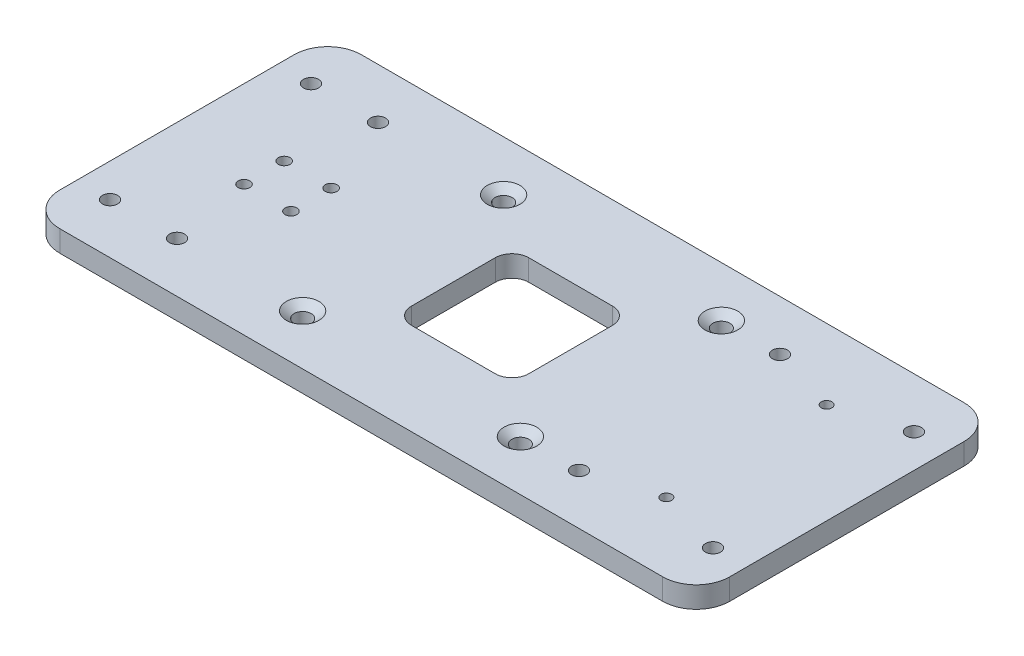
from build123d import *

# Parameters (mm, degrees)
SKETCH1_W                                          = 200
SKETCH1_H                                          = 90
BOSS_EXTRUDE1_DEPTH                                = 6.35
CSK_FOR_10_FLAT_HEAD_MACHINE_SCREW_100_D           = 5.1054
CSK_FOR_10_FLAT_HEAD_MACHINE_SCREW_100_CSINK_D     = 9.779
CSK_FOR_10_FLAT_HEAD_MACHINE_SCREW_100_CSINK_ANGLE = 100
M4_CLEARANCE_HOLE1_D                               = 4.5
SKETCH9_W                                          = 35
SKETCH9_H                                          = 35
CUT_EXTRUDE1_DEPTH                                 = 6.35
FILLET1_R                                          = 10
FILLET2_R                                          = 5
F_8_32_TAPPED_HOLE1_D                              = 3.175
SKETCH15_R                                         = 1.75
CUT_EXTRUDE2_DEPTH                                 = 7.35


with BuildPart() as part:
    # Sketch1 → Boss-Extrude1 (new body)
    with BuildSketch(Plane(origin=(0, 0, 0), x_dir=(1, 0, 0), z_dir=(0, 1, 0))):
        Rectangle(SKETCH1_W, SKETCH1_H)
    extrude(amount=BOSS_EXTRUDE1_DEPTH)

    # CSK for #10 Flat Head Machine Screw (100)1 (through all)
    with Locations(Plane(origin=(0, 6.35, 0), x_dir=(1, 0, 0), z_dir=(0, 1, 0))):
        with Locations((-32.5, 30), (-32.5, -30), (32.5, -30), (32.5, 30)):
            CounterSinkHole(CSK_FOR_10_FLAT_HEAD_MACHINE_SCREW_100_D / 2, CSK_FOR_10_FLAT_HEAD_MACHINE_SCREW_100_CSINK_D / 2, counter_sink_angle=CSK_FOR_10_FLAT_HEAD_MACHINE_SCREW_100_CSINK_ANGLE)

    # M4 Clearance Hole1 (through all)
    with Locations(Plane(origin=(0, 6.35, 0), x_dir=(1, 0, 0), z_dir=(0, 1, 0))):
        with Locations((-90, -30), (-90, 30), (90, 30), (90, -30), (-70, -30), (-70, 30), (50, 30), (50, -30)):
            Hole(M4_CLEARANCE_HOLE1_D / 2)

    # Sketch9 → Cut-Extrude1 (cut)
    with BuildSketch(Plane(origin=(0, 6.35, 0), x_dir=(1, 0, 0), z_dir=(0, 1, 0))):
        Rectangle(SKETCH9_W, SKETCH9_H)
    extrude(amount=-CUT_EXTRUDE1_DEPTH, mode=Mode.SUBTRACT)

    # Fillet1
    fillet1_edges = [part.edges().sort_by_distance(p)[0] for p in [
        (100, 3.175, 45),
        (-100, 3.175, 45),
        (-100, 3.175, -45),
        (100, 3.175, -45),
    ]]
    fillet(fillet1_edges, radius=FILLET1_R)

    # Fillet2
    fillet2_edges = [part.edges().sort_by_distance(p)[0] for p in [
        (17.5, 3.175, -17.5),
        (17.5, 3.175, 17.5),
        (-17.5, 3.175, 17.5),
        (-17.5, 3.175, -17.5),
    ]]
    fillet(fillet2_edges, radius=FILLET2_R)

    # #8-32 Tapped Hole1 (through all)
    with Locations(Plane(origin=(0, 6.35, 0), x_dir=(1, 0, 0), z_dir=(0, 1, 0))):
        with Locations((70, 23.923457084), (70, -23.923457084)):
            Hole(F_8_32_TAPPED_HOLE1_D / 2)

    # Sketch15 → Cut-Extrude2 (cut, through all)
    with BuildSketch(Plane(origin=(0, 0, 0), x_dir=(-1, 0, 0), z_dir=(0, -1, 0))):
        with Locations((74, 6)):
            Circle(SKETCH15_R)
        with Locations((60, 6)):
            Circle(SKETCH15_R)
        with Locations((60, -6)):
            Circle(SKETCH15_R)
        with Locations((74, -6)):
            Circle(SKETCH15_R)
    extrude(amount=-CUT_EXTRUDE2_DEPTH, mode=Mode.SUBTRACT)


solid = part.part
